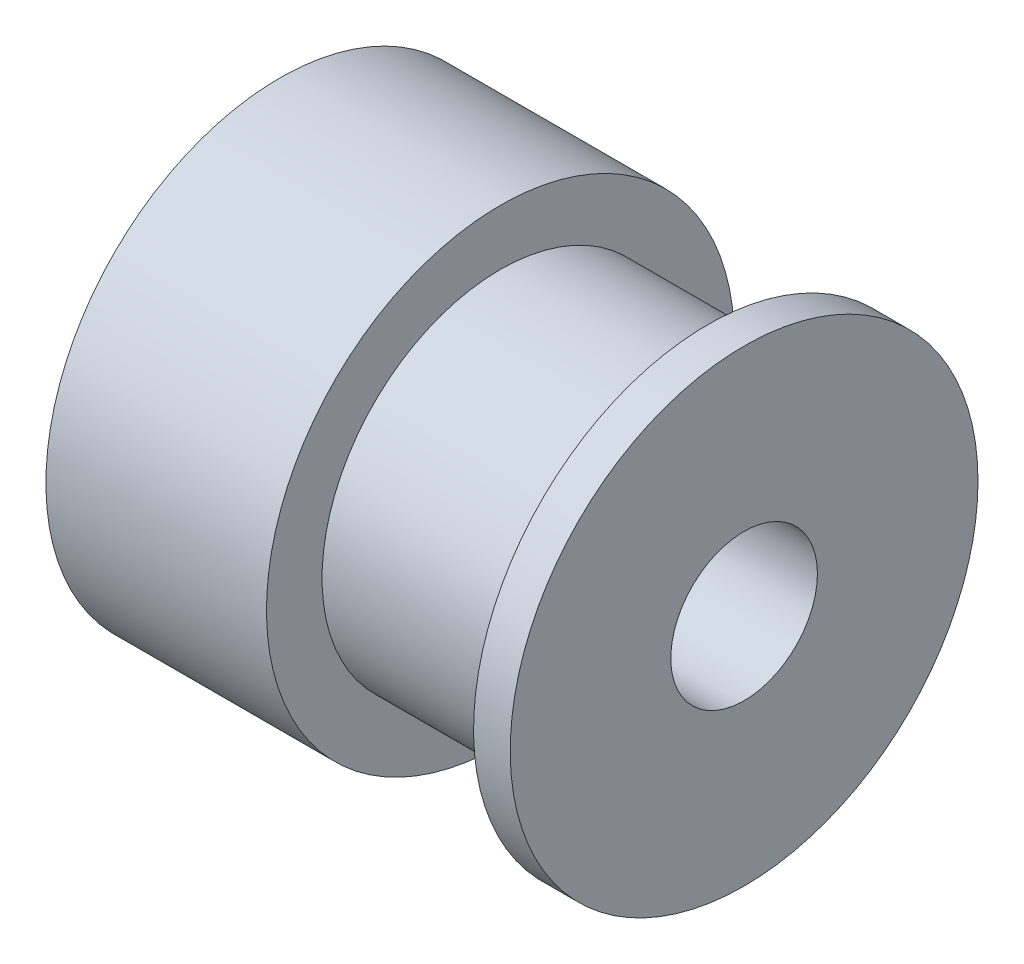
from build123d import *

# Parameters (mm, degrees)
SKETCH1_R           = 7.975
BOSS_EXTRUDE1_DEPTH = 15.83
SKETCH2_W           = 7.06
SKETCH2_H           = 1.895
SKETCH3_R           = 2.5
CUT_EXTRUDE1_DEPTH  = 16.83


with BuildPart() as part:
    # Sketch1 → Boss-Extrude1 (new body)
    with BuildSketch(Plane(origin=(0, 0, 0), x_dir=(0, 0, -1), z_dir=(1, 0, 0))):
        Circle(SKETCH1_R)
    extrude(amount=BOSS_EXTRUDE1_DEPTH)

    # Sketch2 → Cut-Revolve1 (revolve, cut)
    with BuildSketch(Plane.XY):
        with Locations((11.05, 7.0275)):
            Rectangle(SKETCH2_W, SKETCH2_H)
    revolve(axis=Axis((0, 0, 0), (1, 0, 0)), mode=Mode.SUBTRACT)

    # Sketch3 → Cut-Extrude1 (cut, through all)
    with BuildSketch(Plane(origin=(15.83, 0, 0), x_dir=(0, 0, -1), z_dir=(1, 0, 0))):
        Circle(SKETCH3_R)
    extrude(amount=-CUT_EXTRUDE1_DEPTH, mode=Mode.SUBTRACT)


solid = part.part
